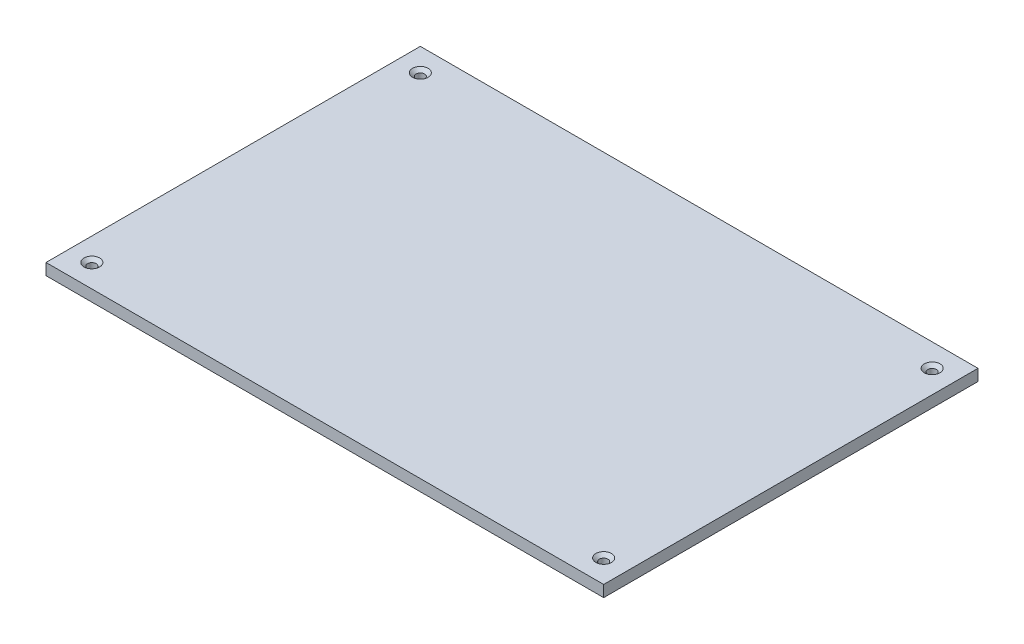
from build123d import *

# Parameters (mm, degrees)
SKETCH1_W           = 463.55
SKETCH1_H           = 311.15
BOSS_EXTRUDE1_DEPTH = 9.525
SKETCH2_R           = 3.571875
CUT_EXTRUDE1_DEPTH  = 9.525
CHAMFER1_SIZE       = 2.921
CHAMFER1_SIZE2      = 2.630080213


with BuildPart() as part:
    # Sketch1 → Boss-Extrude1 (new body)
    with BuildSketch(Plane(origin=(0, 0, 0), x_dir=(1, 0, 0), z_dir=(0, 1, 0))):
        with Locations((231.775, -155.575)):
            Rectangle(SKETCH1_W, SKETCH1_H)
    extrude(amount=BOSS_EXTRUDE1_DEPTH)

    # Sketch2 → Cut-Extrude1 (cut)
    with BuildSketch(Plane(origin=(0, 9.525, 0), x_dir=(1, 0, 0), z_dir=(0, 1, 0))):
        with Locations((444.5, -19.05)):
            Circle(SKETCH2_R)
        with Locations((19.05, -19.05)):
            Circle(SKETCH2_R)
        with Locations((444.5, -292.1)):
            Circle(SKETCH2_R)
        with Locations((19.05, -292.1)):
            Circle(SKETCH2_R)
    extrude(amount=-CUT_EXTRUDE1_DEPTH, mode=Mode.SUBTRACT)

    # Chamfer1
    chamfer1_edges = [part.edges().sort_by_distance(p)[0] for p in [
        (440.928125, 9.525, 19.05),
        (15.478125, 9.525, 19.05),
        (440.928125, 9.525, 292.1),
        (15.478125, 9.525, 292.1),
    ]]
    chamfer1_side = [part.faces().sort_by_distance(p)[0] for p in [
        (231.775, 9.525, 155.575),
    ]]
    chamfer(chamfer1_edges, length=CHAMFER1_SIZE, length2=CHAMFER1_SIZE2, reference=chamfer1_side[0])


solid = part.part
